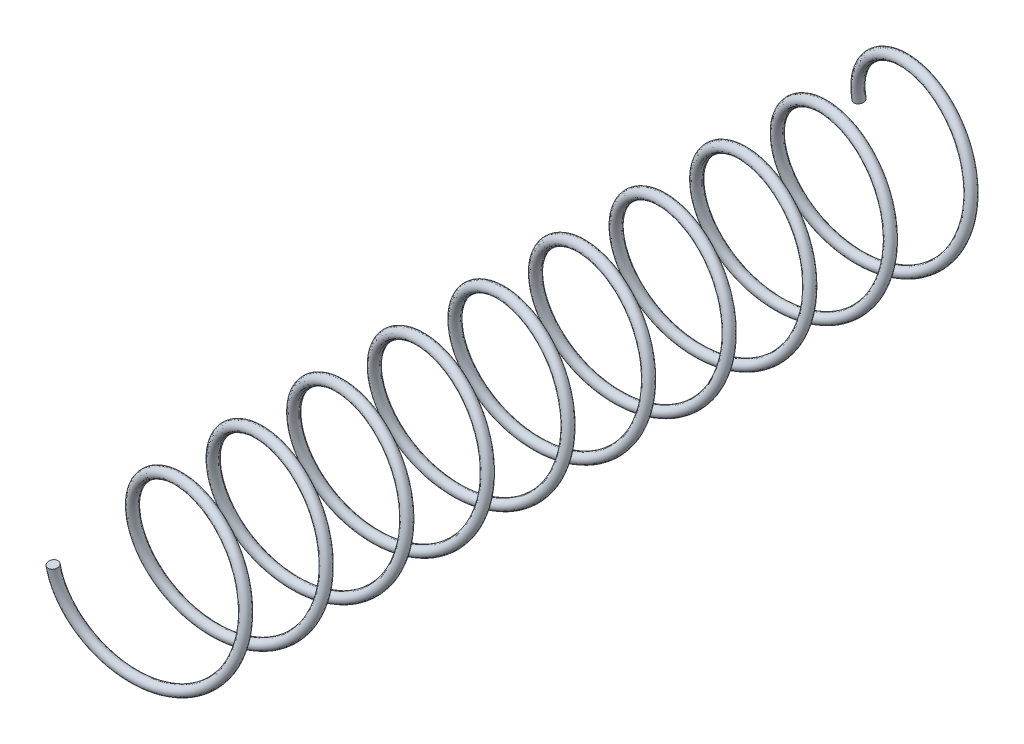
from build123d import *

# Parameters (mm, degrees)
SWEEP1_PITCH       = 8
SWEEP1_HEIGHT      = 80
SWEEP1_RADIUS      = 7.5
SWEEP1_START_ANGLE = -180
SWEEP1_PROFILE_R   = 0.5


with BuildPart() as part:
    # Sweep1: sweep along a helix
    with BuildLine() as sweep1_path:
        add(Helix(SWEEP1_PITCH, SWEEP1_HEIGHT, SWEEP1_RADIUS, center=(0, 0, 0), direction=(0, 0, 1), lefthand=True, mode=Mode.PRIVATE).rotate(Axis((0, 0, 0), (0, 0, 1)), SWEEP1_START_ANGLE))
    # Sweep1 profile (on start of the path) → Sweep1 (sweep)
    with BuildSketch(Plane(origin=(-7.5, 0, 0), x_dir=(0, -0.167370573, 0.985894057), z_dir=(0, 0.985894057, 0.167370573))):
        Circle(SWEEP1_PROFILE_R)
    sweep(path=sweep1_path.line, is_frenet=True)


solid = part.part
